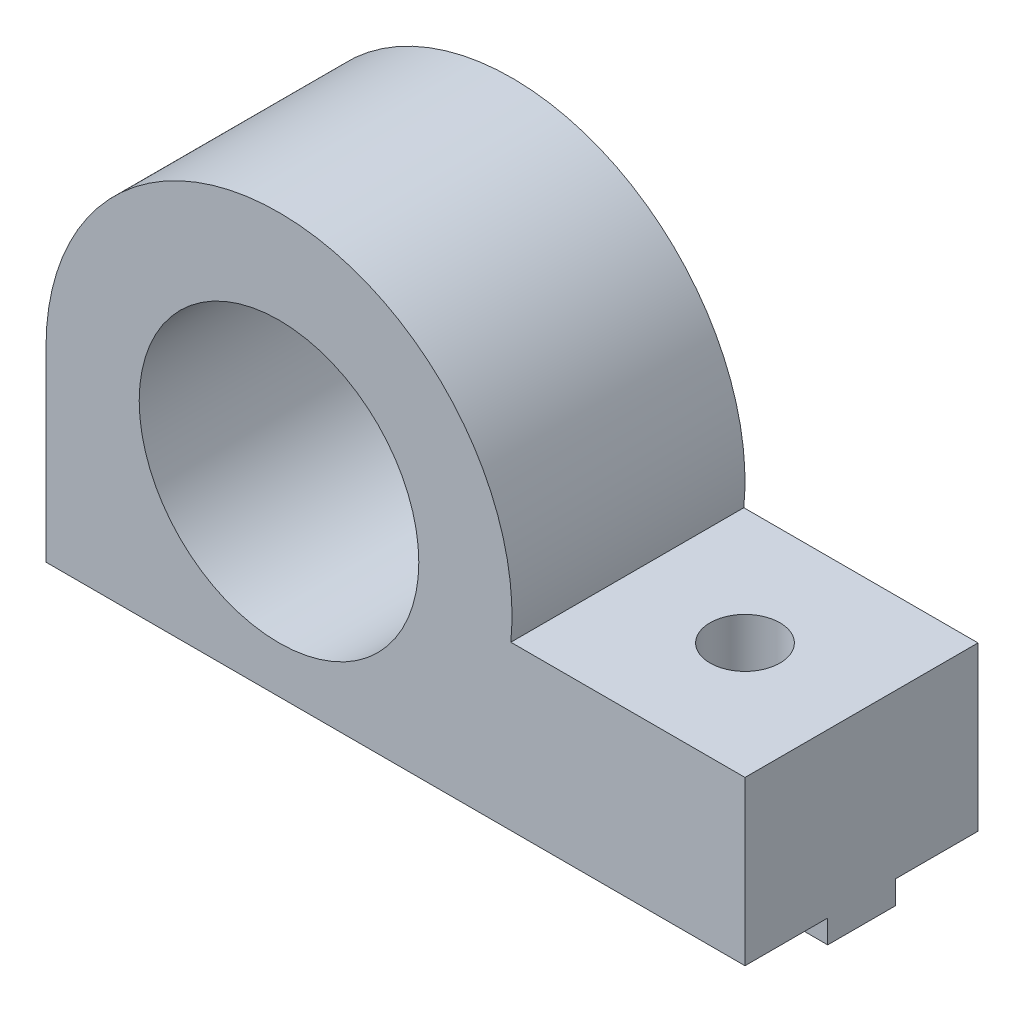
from build123d import *

# Parameters (mm, degrees)
SKETCH1_R                       = 6
MAIN_DEPTH                      = 10
SKETCH3_W                       = 30
SKETCH3_H                       = 2.9
MAKERBEAMRECTANGULARGUIDE_DEPTH = 1
SKETCH4_R                       = 1.5
MAKERBEAMFIXHOLE_DEPTH          = 9


with BuildPart() as part:
    # Sketch1 → Main (new body)
    with BuildSketch(Plane.XY):
        with BuildLine():
            Line((-10, 0), (-10, -8))
            Line((-10, -8), (20, -8))
            Line((20, -8), (20, -1))
            Line((20, -1), (9.949874371, -1))
            ThreePointArc((9.949874371, -1), (0.500627751, 9.987460731), (-10, 0))
        make_face()
        Circle(SKETCH1_R, mode=Mode.SUBTRACT)
    extrude(amount=MAIN_DEPTH)

    # Sketch3 → MakerBeamRectangularGuide (add)
    with BuildSketch(Plane(origin=(0, -8, 0), x_dir=(-1, 0, 0), z_dir=(0, -1, 0))):
        with Locations((-5, -5)):
            Rectangle(SKETCH3_W, SKETCH3_H)
    extrude(amount=MAKERBEAMRECTANGULARGUIDE_DEPTH)

    # Sketch4 → MakerBeamFixHole (cut, through all)
    with BuildSketch(Plane(origin=(0, -1, 0), x_dir=(1, 0, 0), z_dir=(0, 1, 0))):
        with Locations((15, -5)):
            Circle(SKETCH4_R)
    extrude(amount=-MAKERBEAMFIXHOLE_DEPTH, mode=Mode.SUBTRACT)


solid = part.part
